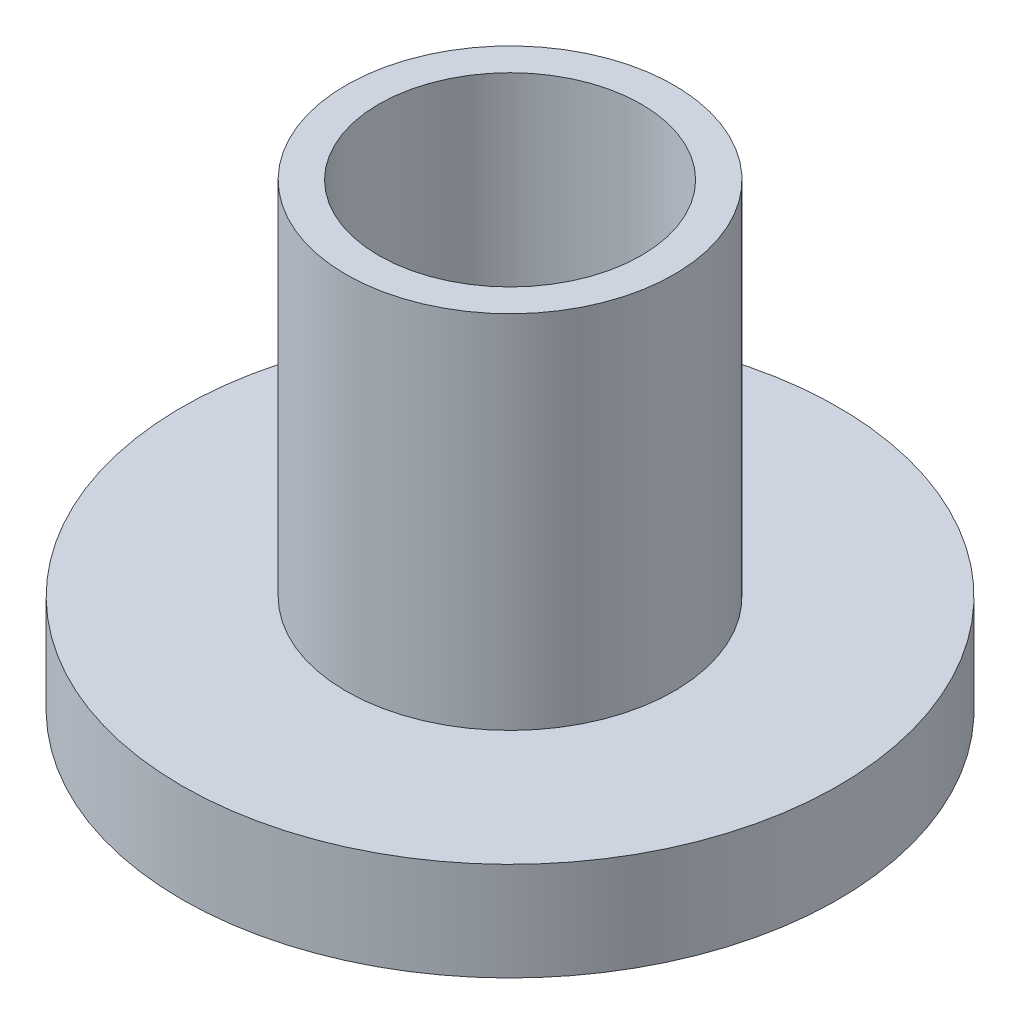
from build123d import *

# Parameters (mm, degrees)
SKETCH_1_R      = 5
SKETCH_1_R_2    = 2
EXTRUDE_1_DEPTH = 1.5
SKETCH_2_R      = 2.5
SKETCH_2_R_2    = 2
EXTRUDE_2_DEPTH = 5.5


with BuildPart() as part:
    # 草图1 → 凸台-拉伸1 (new body)
    with BuildSketch(Plane(origin=(0, 0, 0), x_dir=(1, 0, 0), z_dir=(0, 1, 0))):
        Circle(SKETCH_1_R)
        Circle(SKETCH_1_R_2, mode=Mode.SUBTRACT)
    extrude(amount=EXTRUDE_1_DEPTH)

    # 草图2 → 凸台-拉伸2 (add)
    with BuildSketch(Plane(origin=(0, 1.5, 0), x_dir=(1, 0, 0), z_dir=(0, 1, 0))):
        Circle(SKETCH_2_R)
        Circle(SKETCH_2_R_2, mode=Mode.SUBTRACT)
    extrude(amount=EXTRUDE_2_DEPTH)


solid = part.part
